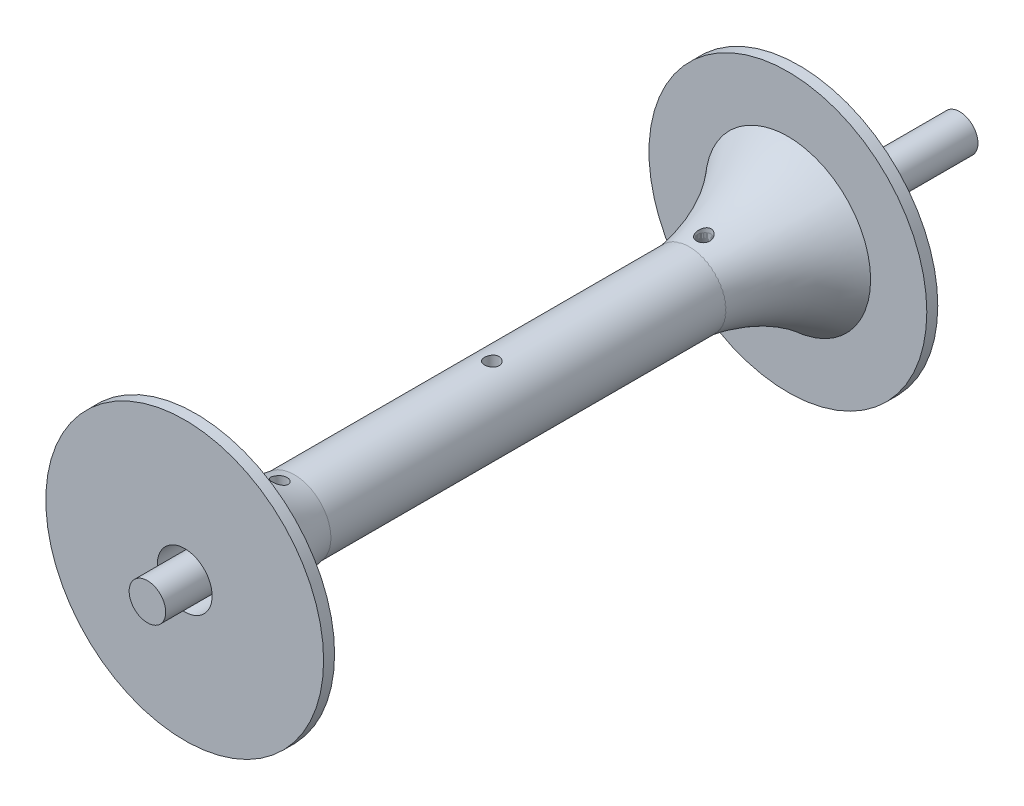
from build123d import *

# Parameters (mm, degrees)
SKETCH1_R               = 6.35
BOSS_EXTRUDE1_DEPTH     = 282.194
SKETCH15_W              = 3.81
SKETCH15_H              = 25.4
SKETCH8_R               = 12.7
BOSS_EXTRUDE2_DEPTH     = 184.658
SKETCH16_R              = 2.54
CUT_EXTRUDE1_DEPTH      = 49.26
CUT_EXTRUDE1_DEPTH_BACK = 49.26


with BuildPart() as part:
    # Sketch1 → Boss-Extrude1 (new body)
    with BuildSketch(Plane.XY):
        Circle(SKETCH1_R)
    extrude(amount=BOSS_EXTRUDE1_DEPTH)


with BuildPart() as body_2:
    # Sketch14 → Revolve1 (revolve)
    with BuildSketch(Plane(origin=(0, 0, 0), x_dir=(0, 0, -1), z_dir=(1, 0, 0))):
        with BuildLine():
            Line((-106.68, 9.525), (-55.88, 9.525))
            Line((-55.88, 9.525), (-55.88, 32.385))
            ThreePointArc((-55.88, 32.385), (-79.076676753, 16.716691883), (-106.68, 12.065))
            Line((-106.68, 12.065), (-106.68, 9.525))
        make_face()
    revolve1 = revolve(axis=Axis((0, 0, 282.194), (0, 0, -1)))


with BuildPart() as body_3:
    # Sketch15 → Revolve2 (revolve)
    with BuildSketch(Plane(origin=(0, 0, 0), x_dir=(0, 0, -1), z_dir=(1, 0, 0))):
        with Locations((-57.785, 35.56)):
            Rectangle(SKETCH15_W, SKETCH15_H)
    revolve2 = revolve(axis=Axis((0, 0, 282.194), (0, 0, -1)))


with BuildPart() as body_4:
    # Sketch8 → Boss-Extrude2 (new body)
    with BuildSketch(Plane(origin=(0, 0, 55.88), x_dir=(-1, 0, 0), z_dir=(0, 0, -1))):
        Circle(SKETCH8_R)
    extrude(amount=-BOSS_EXTRUDE2_DEPTH)

    # Mirror6: Revolve1, Revolve2 across plane
    add(revolve1.mirror(Plane(origin=(0, 0, 162.56), x_dir=(1, 0, 0), z_dir=(0, 0, -1))))
    add(revolve2.mirror(Plane(origin=(0, 0, 162.56), x_dir=(1, 0, 0), z_dir=(0, 0, -1))))


with BuildPart() as cut_extrude1_tool:
    # Sketch16 → Cut-Extrude1 (new body, two sides)
    with BuildSketch(Plane(origin=(0, 0, 0), x_dir=(1, 0, 0), z_dir=(0, 1, 0))) as cut_extrude1_sk:
        with Locations((0, -88.9)):
            Circle(SKETCH16_R)
        with Locations((0, -162.56)):
            Circle(SKETCH16_R)
        with Locations((0, -236.22)):
            Circle(SKETCH16_R)
    extrude(amount=CUT_EXTRUDE1_DEPTH)
    extrude(cut_extrude1_sk.sketch, amount=-CUT_EXTRUDE1_DEPTH_BACK)


with BuildPart() as part_1:
    add(part.part)

    # Cut-Extrude1: cut by cut_extrude1_tool
    add(cut_extrude1_tool.part, mode=Mode.SUBTRACT)


with BuildPart() as body_2_1:
    add(body_2.part)

    # Cut-Extrude1: cut by cut_extrude1_tool
    add(cut_extrude1_tool.part, mode=Mode.SUBTRACT)


with BuildPart() as body_4_1:
    add(body_4.part)

    # Cut-Extrude1: cut by cut_extrude1_tool
    add(cut_extrude1_tool.part, mode=Mode.SUBTRACT)


solid = Compound([body_3.part, part_1.part, body_2_1.part, body_4_1.part])
